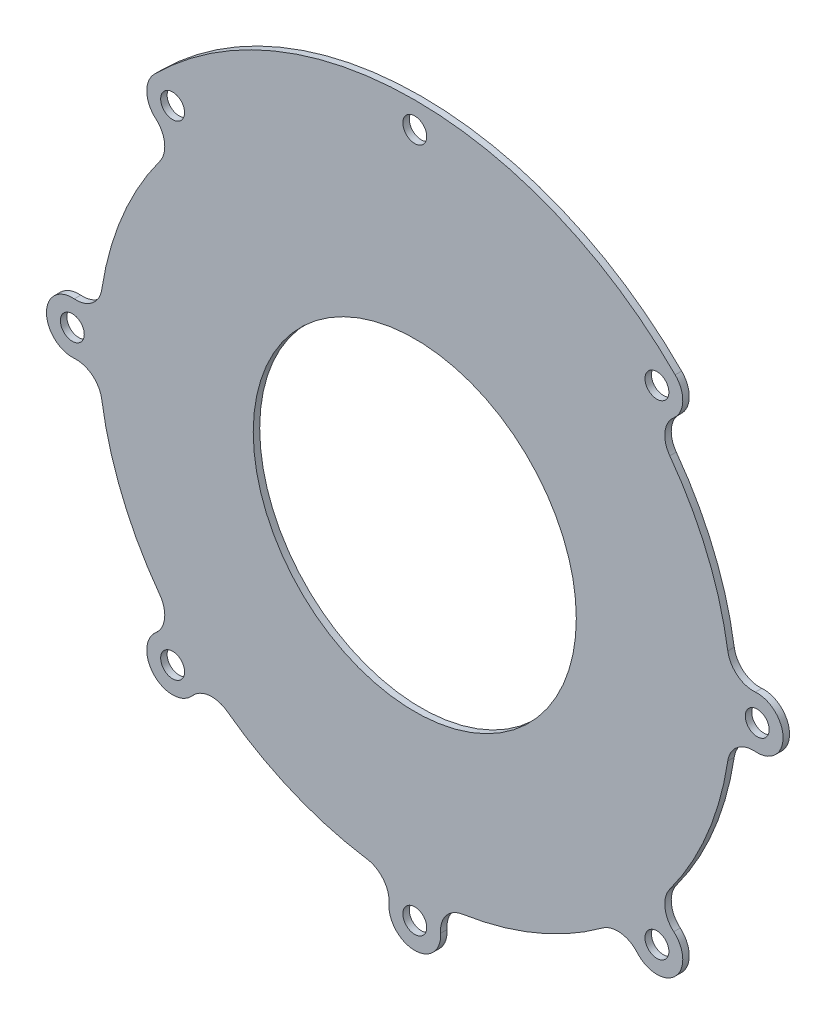
from build123d import *

# Parameters (mm, degrees)
NPTH_R              = 1.85
NPTH_R_2            = 25
BOSS_EXTRUDE1_DEPTH = 1


with BuildPart() as part:
    # NPTH → Boss-Extrude1 (new body)
    with BuildSketch(Plane.XY):
        with BuildLine():
            ThreePointArc((33.779497471, 45.912368166), (-4.301886792, 56.837432824), (-40.305086528, 40.305086528))
            ThreePointArc((-40.305086528, 40.305086528), (-41.47380633, 37.325608267), (-40.083553498, 34.442832912))
            ThreePointArc((-40.083553498, 34.442832912), (-38.716100837, 31.861298217), (-39.46852702, 29.03851537))
            ThreePointArc((-39.46852702, 29.03851537), (-45.270097093, 18.751488186), (-48.441794233, 7.375131965))
            ThreePointArc((-48.441794233, 7.375131965), (-49.90575747, 4.847077417), (-52.698113208, 3.988591777))
            ThreePointArc((-52.698113208, 3.988591777), (-57, 0), (-52.698113208, -3.988591777))
            ThreePointArc((-52.698113208, -3.988591777), (-49.90575747, -4.847077417), (-48.441794233, -7.375131965))
            ThreePointArc((-48.441794233, -7.375131965), (-45.270097093, -18.751488186), (-39.46852702, -29.03851537))
            ThreePointArc((-39.46852702, -29.03851537), (-38.716100837, -31.861298217), (-40.083553498, -34.442832912))
            ThreePointArc((-40.083553498, -34.442832912), (-40.305086528, -40.305086528), (-34.442832912, -40.083553498))
            ThreePointArc((-34.442832912, -40.083553498), (-31.861298217, -38.716100837), (-29.03851537, -39.46852702))
            ThreePointArc((-29.03851537, -39.46852702), (-18.751488186, -45.270097093), (-7.375131965, -48.441794233))
            ThreePointArc((-7.375131965, -48.441794233), (-4.847077417, -49.90575747), (-3.988591777, -52.698113208))
            ThreePointArc((-3.988591777, -52.698113208), (0, -57), (3.988591777, -52.698113208))
            ThreePointArc((3.988591777, -52.698113208), (4.847077417, -49.90575747), (7.375131965, -48.441794233))
            ThreePointArc((7.375131965, -48.441794233), (18.751488186, -45.270097093), (29.03851537, -39.46852702))
            ThreePointArc((29.03851537, -39.46852702), (31.861298217, -38.716100837), (34.442832912, -40.083553498))
            ThreePointArc((34.442832912, -40.083553498), (40.305086528, -40.305086528), (40.083553498, -34.442832912))
            ThreePointArc((40.083553498, -34.442832912), (38.716100837, -31.861298217), (39.46852702, -29.03851537))
            ThreePointArc((39.46852702, -29.03851537), (45.270097093, -18.751488186), (48.441794233, -7.375131965))
            ThreePointArc((48.441794233, -7.375131965), (49.90575747, -4.847077417), (52.698113208, -3.988591777))
            ThreePointArc((52.698113208, -3.988591777), (57, 0), (52.698113208, 3.988591777))
            ThreePointArc((52.698113208, 3.988591777), (49.90575747, 4.847077417), (48.441794233, 7.375131965))
            ThreePointArc((48.441794233, 7.375131965), (45.270097093, 18.751488186), (39.46852702, 29.03851537))
            ThreePointArc((39.46852702, 29.03851537), (38.716100837, 31.861298217), (40.083553498, 34.442832912))
            ThreePointArc((40.083553498, 34.442832912), (41.47380633, 37.325608267), (40.305086528, 40.305086528))
            ThreePointArc((40.305086528, 40.305086528), (37.148240852, 43.232027498), (33.779497471, 45.912368166))
        make_face()
        with Locations((-37.476659403, -37.476659403)):
            Circle(NPTH_R, mode=Mode.SUBTRACT)
        with Locations((-53, 0)):
            Circle(NPTH_R, mode=Mode.SUBTRACT)
        with Locations((0, -53)):
            Circle(NPTH_R, mode=Mode.SUBTRACT)
        with Locations((37.476659403, -37.476659403)):
            Circle(NPTH_R, mode=Mode.SUBTRACT)
        Circle(NPTH_R_2, mode=Mode.SUBTRACT)
        with Locations((53, 0)):
            Circle(NPTH_R, mode=Mode.SUBTRACT)
        with Locations((-37.476659403, 37.476659403)):
            Circle(NPTH_R, mode=Mode.SUBTRACT)
        with Locations((0, 53)):
            Circle(NPTH_R, mode=Mode.SUBTRACT)
        with Locations((37.476659403, 37.476659403)):
            Circle(NPTH_R, mode=Mode.SUBTRACT)
    extrude(amount=BOSS_EXTRUDE1_DEPTH)


solid = part.part
